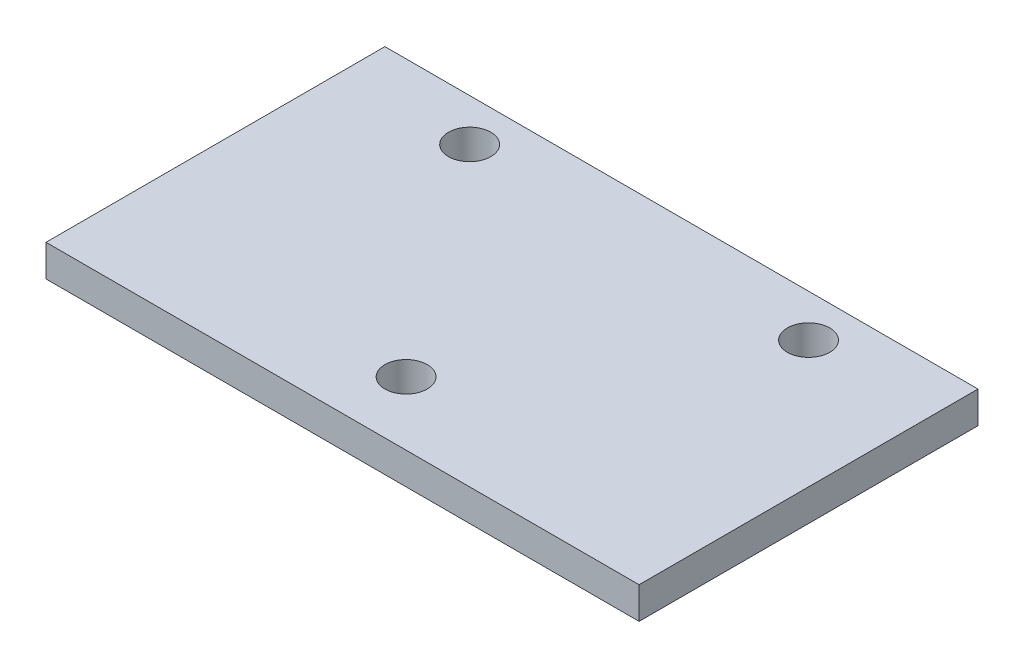
from build123d import *

# Parameters (mm, degrees)
SKETCH1_W   = 177.8
SKETCH1_H   = 101.6
PLATE_DEPTH = 9.525
SKETCH2_R   = 6.35
HOLES_DEPTH = 10.525


with BuildPart() as part:
    # Sketch1 → Plate (new body)
    with BuildSketch(Plane(origin=(0, 0, 0), x_dir=(1, 0, 0), z_dir=(0, 1, 0))):
        Rectangle(SKETCH1_W, SKETCH1_H)
    extrude(amount=PLATE_DEPTH)

    # Sketch2 → Holes (cut, through all)
    with BuildSketch(Plane(origin=(0, 9.525, 0), x_dir=(-1, 0, 0), z_dir=(0, 1, 0))):
        with Locations((50.8, -38.1)):
            Circle(SKETCH2_R)
        with Locations((-50.8, -38.1)):
            Circle(SKETCH2_R)
        with Locations((0, 31.75)):
            Circle(SKETCH2_R)
    extrude(amount=-HOLES_DEPTH, mode=Mode.SUBTRACT)


solid = part.part
